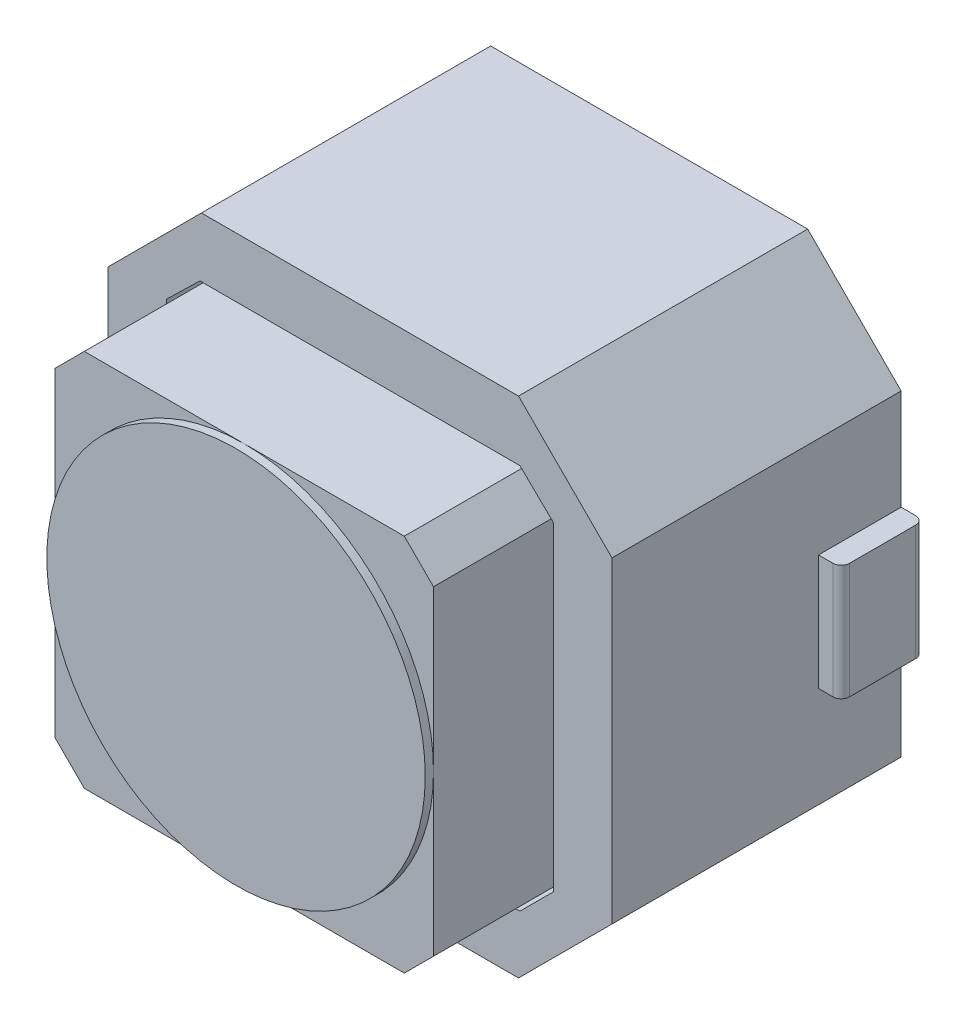
from build123d import *

# Parameters (mm, degrees)
EXTRUDE_1_DEPTH        = 3.5
EXTRUDE_2_DEPTH        = 1.5
SKETCH_3_OUTSIDE_W     = 10.094
SKETCH_3_OUTSIDE_H     = 10.094
SKETCH_3_OUTSIDE_R     = 2.29
CUT_EXTRUDE_1_DEPTH    = 0.1
SKETCH_4_W             = 1
SKETCH_4_H             = 1.4
EXTRUDE_3_DEPTH        = 0.275
FILLET_1_R             = 0.1
FILLET_1_OF_MIRROR_1_R = 0.1
CUT_EXTRUDE_2_DEPTH    = 2


with BuildPart() as part:
    # 草图1 → 凸台-拉伸1 (new body)
    with BuildSketch(Plane.XY):
        Polygon((-1.91862915, -3.05), (1.91862915, -3.05), (3.05, -1.91862915), (3.05, 1.91862915), (1.91862915, 3.05), (-1.91862915, 3.05), (-3.05, 1.91862915), (-3.05, -1.91862915), align=None)
    extrude(amount=EXTRUDE_1_DEPTH)

    # 草图2 → 凸台-拉伸2 (add)
    with BuildSketch(Plane.XY.offset(3.5)):
        Polygon((2.29, -1.936446609), (1.936446609, -2.29), (-1.936446609, -2.29), (-2.29, -1.936446609), (-2.29, 1.936446609), (-1.936446609, 2.29), (1.936446609, 2.29), (2.29, 1.936446609), align=None)
    extrude(amount=EXTRUDE_2_DEPTH)

    # 草图3 outside → 切除-拉伸1 (cut)
    with BuildSketch(Plane.XY.offset(5)):
        Rectangle(SKETCH_3_OUTSIDE_W, SKETCH_3_OUTSIDE_H)
        Circle(SKETCH_3_OUTSIDE_R, mode=Mode.SUBTRACT)
    cut_extrude_1 = extrude(amount=-CUT_EXTRUDE_1_DEPTH, mode=Mode.SUBTRACT)

    # 草图4 → 凸台-拉伸3 (add)
    with BuildSketch(Plane.ZY.offset(3.05)):
        with Locations((0.5, 0)):
            Rectangle(SKETCH_4_W, SKETCH_4_H)
    extrude_3 = extrude(amount=EXTRUDE_3_DEPTH)

    # 圆角1
    fillet_1_edges = [part.edges().sort_by_distance(p)[0] for p in [
        (-3.325, 0, 1),
        (-3.325, 0, 0),
    ]]
    fillet(fillet_1_edges, radius=FILLET_1_R)

    # 镜向1: 切除-拉伸1, 凸台-拉伸3 across plane
    add(cut_extrude_1.mirror(Plane(origin=(0, 0, 0), x_dir=(0, 0, 1), z_dir=(1, 0, 0))), mode=Mode.SUBTRACT)
    add(extrude_3.mirror(Plane(origin=(0, 0, 0), x_dir=(0, 0, 1), z_dir=(1, 0, 0))))

    # 圆角1 of 镜向1
    fillet_1_of_mirror_1_edges = [part.edges().sort_by_distance(p)[0] for p in [
        (3.325, 0, 1),
        (3.325, 0, 0),
    ]]
    fillet(fillet_1_of_mirror_1_edges, radius=FILLET_1_OF_MIRROR_1_R)

    # 草图5 → 切除-拉伸2 (cut)
    with BuildSketch(Plane.XY.offset(3.5)):
        Polygon((-2.34, 1.936446609), (-2.34, -1.936446609), (-1.936446609, -2.34), (1.936446609, -2.34), (2.34, -1.936446609), (2.34, 1.936446609), (1.936446609, 2.328890946), (-1.936446609, 2.328890946), align=None)
        Polygon((-2.29, 1.936446609), (-1.936446609, 2.29), (1.936446609, 2.29), (2.29, 1.936446609), (2.29, -1.936446609), (1.936446609, -2.29), (-1.936446609, -2.29), (-2.29, -1.936446609), align=None, mode=Mode.SUBTRACT)
    extrude(amount=-CUT_EXTRUDE_2_DEPTH, mode=Mode.SUBTRACT)


solid = part.part
